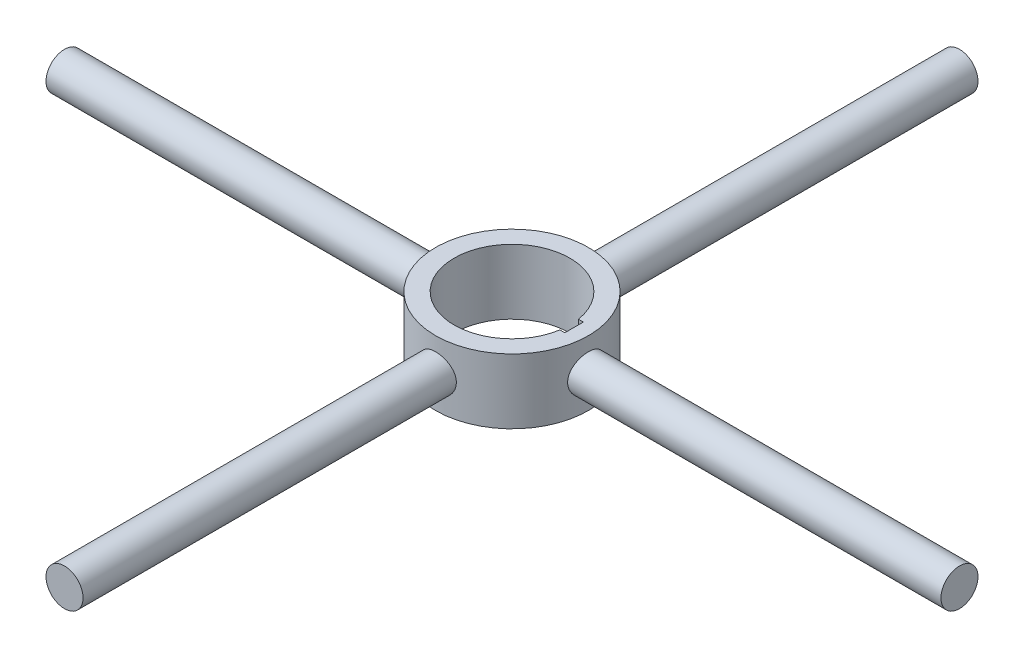
from build123d import *

# Parameters (mm, degrees)
IZIM1_R                     = 82.5
IZIM1_R_2                   = 62.5
Y_KSEKLIK_EKSTR_ZYON1_DEPTH = 70
IZIM2_R                     = 20
Y_KSEKLIK_EKSTR_ZYON2_DEPTH = 405
DAIRESEL_KAPLAMA1_COUNT     = 4
IZIM4_W                     = 15
IZIM4_H                     = 20
KES_EKSTR_ZYON1_DEPTH       = 71.0000001


with BuildPart() as part:
    # Çizim1 → Yükseklik-Ekstrüzyon1 (new body)
    with BuildSketch(Plane(origin=(0, 0, 0), x_dir=(1, 0, 0), z_dir=(0, 1, 0))):
        Circle(IZIM1_R)
        Circle(IZIM1_R_2, mode=Mode.SUBTRACT)
    extrude(amount=Y_KSEKLIK_EKSTR_ZYON1_DEPTH)

    # Çizim2 → Yükseklik-Ekstrüzyon2 (add)
    with BuildSketch(Plane(origin=(77.904802992, 0, 0), x_dir=(0, 0, -1), z_dir=(1, 0, 0))):
        with Locations((0, 35)):
            Circle(IZIM2_R)
    y_kseklik_ekstr_zyon2 = extrude(amount=Y_KSEKLIK_EKSTR_ZYON2_DEPTH)

    # Dairesel Kaplama1: Yükseklik-Ekstrüzyon2 ×4 about axis
    dairesel_kaplama1_axis = Axis((0, 0, 0), (0, 1, 0))
    for i in range(1, DAIRESEL_KAPLAMA1_COUNT):
        add(y_kseklik_ekstr_zyon2.rotate(dairesel_kaplama1_axis, i * 360 / DAIRESEL_KAPLAMA1_COUNT))

    # Çizim4 → Kes-Ekstrüzyon1 (cut, through all)
    with BuildSketch(Plane(origin=(0, 70, 0), x_dir=(1, 0, 0), z_dir=(0, 1, 0))):
        with Locations((59.5, 0)):
            Rectangle(IZIM4_W, IZIM4_H)
    extrude(amount=-KES_EKSTR_ZYON1_DEPTH, mode=Mode.SUBTRACT)


solid = part.part
